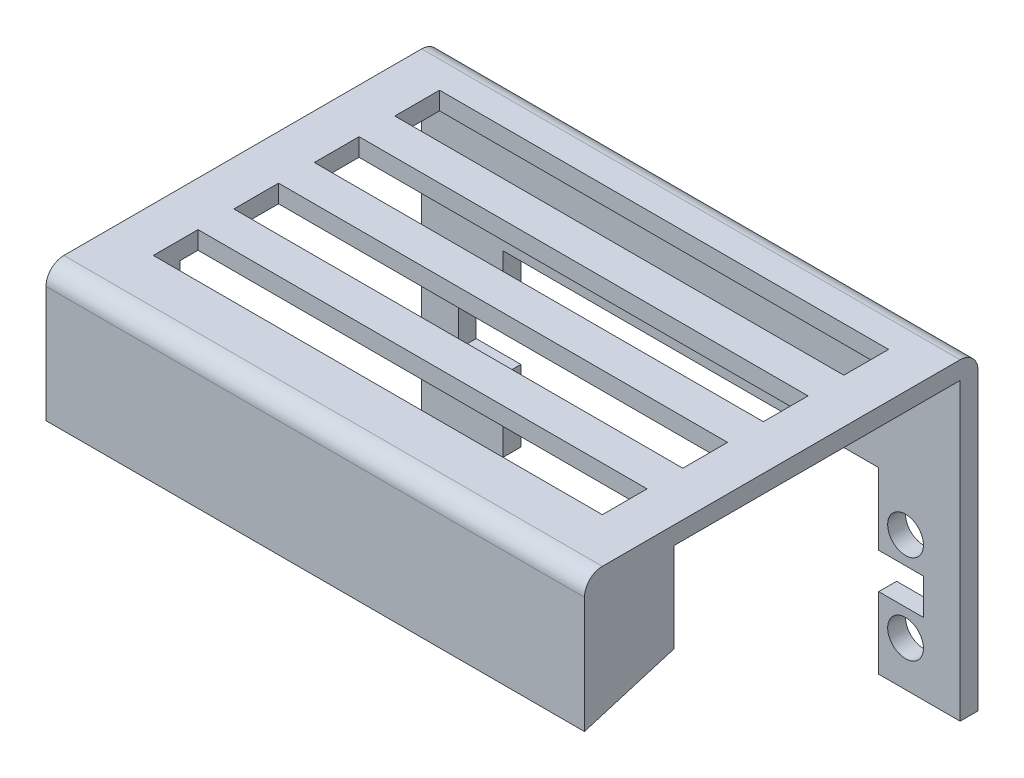
from build123d import *

# Parameters (mm, degrees)
BOSS_EXTRUDE1_DEPTH = 60.2
SKETCH3_R           = 2
CUT_EXTRUDE1_DEPTH  = 20
SKETCH4_W           = 50.2
SKETCH4_H           = 5
CUT_EXTRUDE2_DEPTH  = 20
LPATTERN1_COUNT     = 4
LPATTERN1_PITCH     = 9
FILLET1_R           = 2


with BuildPart() as part:
    # Sketch1 → Boss-Extrude1 (new body)
    with BuildSketch(Plane(origin=(0, 0, 0), x_dir=(0, 0, -1), z_dir=(1, 0, 0))):
        Polygon((0, 0), (0, 15), (44, 15), (44, -20), (42, -20), (42, 13), (10, 13), (10, 3), align=None)
    extrude(amount=-BOSS_EXTRUDE1_DEPTH)

    # Sketch3 → Cut-Extrude1 (cut)
    with BuildSketch(Plane(origin=(0, 0, -44), x_dir=(-1, 0, 0), z_dir=(0, 0, -1))):
        with Locations((54.1, -15)):
            Circle(SKETCH3_R)
        with Locations((54.1, -5)):
            Circle(SKETCH3_R)
        with Locations((6.1, -15)):
            Circle(SKETCH3_R)
        with Locations((6.1, -5)):
            Circle(SKETCH3_R)
        Polygon((9.1, -8), (9.1, 0), (51.1, 0), (51.1, -8), (56.1, -8), (56.1, -12), (51.1, -12), (51.1, -20), (9.1, -20), (9.1, -12), (4.1, -12), (4.1, -8), align=None)
    extrude(amount=-CUT_EXTRUDE1_DEPTH, mode=Mode.SUBTRACT)

    # Sketch4 → Cut-Extrude2 (cut)
    with BuildSketch(Plane(origin=(0, 15, 0), x_dir=(1, 0, 0), z_dir=(0, 1, 0))):
        with Locations((-30.1, 36.5)):
            Rectangle(SKETCH4_W, SKETCH4_H)
    cut_extrude2 = extrude(amount=-CUT_EXTRUDE2_DEPTH, mode=Mode.SUBTRACT)

    # LPattern1: Cut-Extrude2 ×4
    with Locations(*[(0, 0, i * LPATTERN1_PITCH) for i in range(1, LPATTERN1_COUNT)]):
        add(cut_extrude2, mode=Mode.SUBTRACT)

    # Fillet1
    fillet1_edges = [part.edges().sort_by_distance(p)[0] for p in [
        (-30.1, 15, 0),
        (-30.1, 15, -44),
    ]]
    fillet(fillet1_edges, radius=FILLET1_R)


solid = part.part
